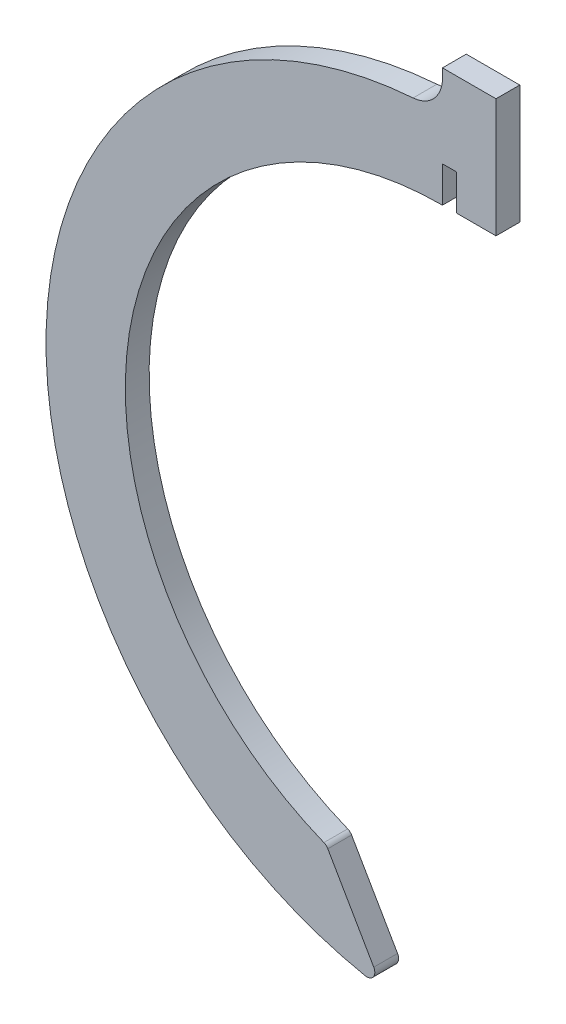
from build123d import *

# Parameters (mm, degrees)
SKETCH1_W           = 6.75
SKETCH1_H           = 5
BOSS_EXTRUDE1_DEPTH = 3
FILLET3_R           = 1
FILLET4_R           = 1
FILLET6_R           = 4


with BuildPart() as part:
    # Sketch1 → Boss-Extrude1 (new body)
    with BuildSketch(Plane.XY):
        with Locations((3.375, 52.5)):
            Rectangle(SKETCH1_W, SKETCH1_H)
        with BuildLine():
            Line((0, 50), (6.75, 50))
            Line((6.75, 50), (6.75, 40.02))
            Line((6.75, 40.02), (1.79, 40.02))
            Line((1.79, 40.02), (1.79, 44.518418243))
            Line((1.79, 44.518418243), (0, 44.518418243))
            Line((0, 44.518418243), (0, 40))
            ThreePointArc((0, 40), (-39.300483317, 7.44795348), (-14.635408574, -37.226399448))
            Line((-14.635408574, -37.226399448), (-7.59560281, -49.419700707))
            ThreePointArc((-7.59560281, -49.419700707), (-49.854714097, 3.808868904), (0, 50))
        make_face()
    extrude(amount=BOSS_EXTRUDE1_DEPTH)

    # Fillet3
    fillet3_edges = [part.edges().sort_by_distance(p)[0] for p in [
        (-7.59560281, -49.419700707, 1.5),
    ]]
    fillet(fillet3_edges, radius=FILLET3_R)

    # Fillet4
    fillet4_edges = [part.edges().sort_by_distance(p)[0] for p in [
        (-14.635408574, -37.226399448, 1.5),
    ]]
    fillet(fillet4_edges, radius=FILLET4_R)

    # Fillet6
    fillet6_edges = [part.edges().sort_by_distance(p)[0] for p in [
        (0, 50, 1.5),
    ]]
    fillet(fillet6_edges, radius=FILLET6_R)


solid = part.part
